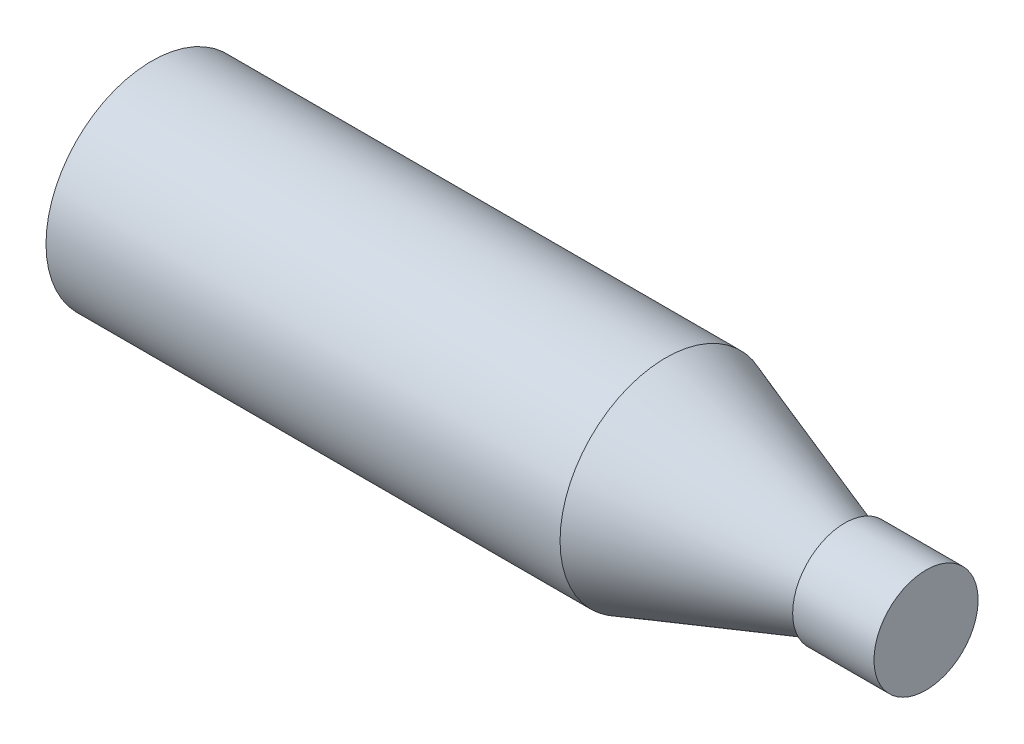
from build123d import *


with BuildPart() as part:
    # Эскиз1 → Повернуть1 (revolve)
    with BuildSketch(Plane.XY, mode=Mode.PRIVATE) as revolve_1_sk:
        Polygon((-50.774937895, 0), (-50.774937895, 32.5), (107.225062105, 32.5), (162.225062105, 13.5), (162.225062105, 16), (187.225062105, 16), (187.225062105, 0), align=None)
    revolve(revolve_1_sk.sketch.rotate(Axis((-50.774937895, 0, 0), (1, 0, 0)), 90), axis=Axis((-50.774937895, 0, 0), (1, 0, 0)))  # turned: the seam where the file's is


solid = part.part
